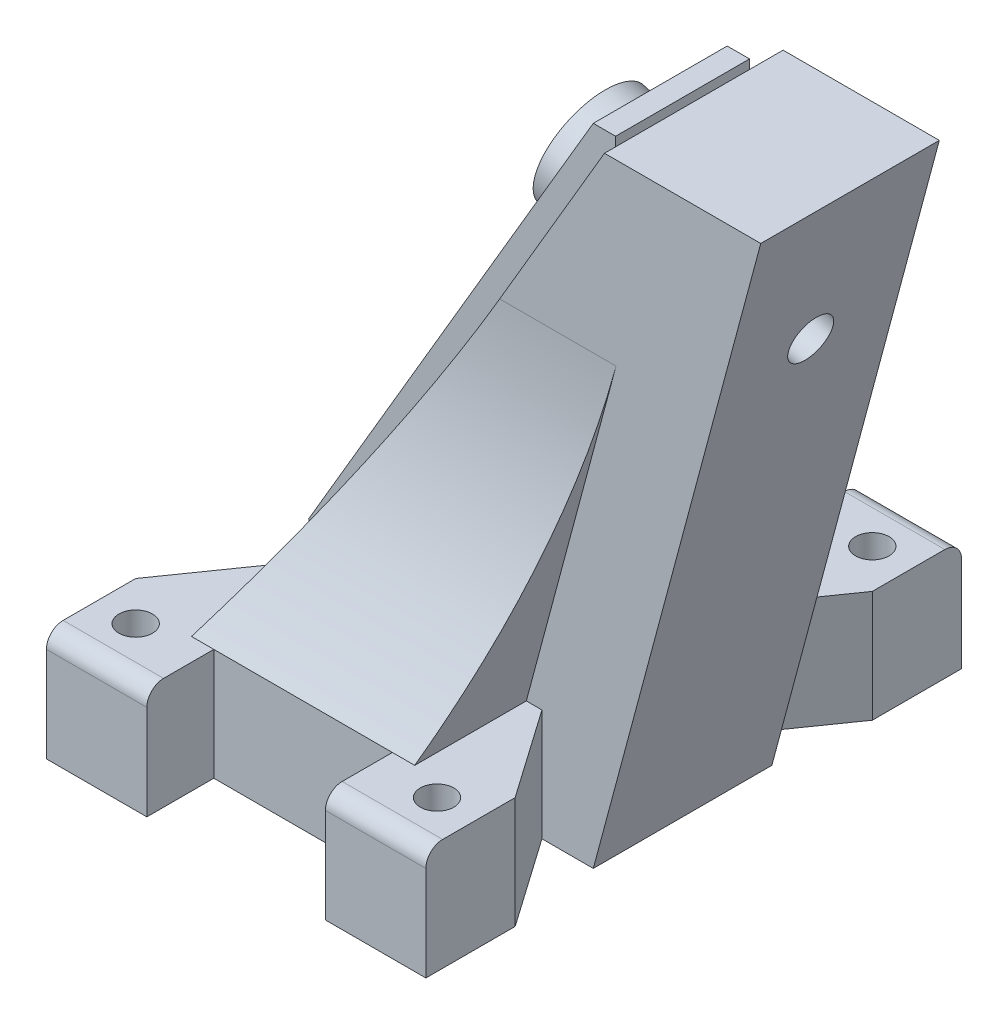
from build123d import *

# Parameters (mm, degrees)
BOSS_EXTRUDE1_DEPTH = 36
CUT_EXTRUDE1_REACH  = 77.774
SKETCH5_W           = 10
SKETCH5_H           = 10
CUT_EXTRUDE4_DEPTH  = 70.808427336
SKETCH6_W           = 10
SKETCH6_H           = 49.869122111
CUT_EXTRUDE5_DEPTH  = 8.383745
SKETCH7_R           = 1.5
BOSS_EXTRUDE2_DEPTH = 10
BOSS_EXTRUDE3_DEPTH = 6
SKETCH9_R           = 5
BOSS_EXTRUDE4_DEPTH = 20.4
CUT_EXTRUDE7_REACH  = 76.44
SKETCH12_R          = 2
FILLET1_R           = 1.5


with BuildPart() as part:
    # Sketch1 → Boss-Extrude1 (new body)
    with BuildSketch(Plane.XY):
        Polygon((0, 0), (-26, 0), (-26, 10), (1.005154776, 56), (15.005154776, 56), align=None)
    extrude(amount=BOSS_EXTRUDE1_DEPTH)

    # Sketch2 → Cut-Extrude1 (cut, up to next)
    with BuildSketch(Plane(origin=(-26, 3.422964937, 0), x_dir=(0, 0, -1), z_dir=(1, 0, 0)), mode=Mode.PRIVATE) as cut_extrude1_sk1:
        with BuildLine():
            Line((-26, 36.577035063), (-26, 52.577035063))
            Line((-26, 52.577035063), (-36, 52.577035063))
            Line((-36, 52.577035063), (-36, 6.577035063))
            ThreePointArc((-36, 6.577035063), (-28.565835097, 20.765646762), (-26, 36.577035063))
        make_face()
    cut_extrude1_tool1 = extrude(cut_extrude1_sk1.sketch, amount=CUT_EXTRUDE1_REACH, mode=Mode.PRIVATE) & part.part
    # Sketch2 → Cut-Extrude1 (cut, up to next)
    with BuildSketch(Plane(origin=(-26, 3.422964937, 0), x_dir=(0, 0, -1), z_dir=(1, 0, 0)), mode=Mode.PRIVATE) as cut_extrude1_sk2:
        with BuildLine():
            ThreePointArc((-10, 36.577035063), (-7.434164903, 20.765646762), (0, 6.577035063))
            Line((0, 6.577035063), (0, 52.577035063))
            Line((0, 52.577035063), (-10, 52.577035063))
            Line((-10, 52.577035063), (-10, 36.577035063))
        make_face()
    cut_extrude1_tool2 = extrude(cut_extrude1_sk2.sketch, amount=CUT_EXTRUDE1_REACH, mode=Mode.PRIVATE) & part.part
    # Sketch2 → Cut-Extrude1 (cut, up to next)
    with BuildSketch(Plane(origin=(-26, 3.422964937, 0), x_dir=(0, 0, -1), z_dir=(1, 0, 0)), mode=Mode.PRIVATE) as cut_extrude1_sk3:
        with BuildLine():
            ThreePointArc((-36, 6.577035063), (-28.565835097, 20.765646762), (-26, 36.577035063))
            Line((-26, 36.577035063), (-26, 52.577035063))
            Line((-26, 52.577035063), (-36, 52.577035063))
            Line((-36, 52.577035063), (-36, 6.577035063))
        make_face()
    cut_extrude1_tool3 = extrude(cut_extrude1_sk3.sketch, amount=CUT_EXTRUDE1_REACH, mode=Mode.PRIVATE) & part.part
    # Sketch2 → Cut-Extrude1 (cut, up to next)
    with BuildSketch(Plane(origin=(-26, 3.422964937, 0), x_dir=(0, 0, -1), z_dir=(1, 0, 0)), mode=Mode.PRIVATE) as cut_extrude1_sk4:
        with BuildLine():
            Line((0, 6.577035063), (0, 52.577035063))
            Line((0, 52.577035063), (-10, 52.577035063))
            Line((-10, 52.577035063), (-10, 36.577035063))
            ThreePointArc((-10, 36.577035063), (-7.434164903, 20.765646762), (0, 6.577035063))
        make_face()
    cut_extrude1_tool4 = extrude(cut_extrude1_sk4.sketch, amount=CUT_EXTRUDE1_REACH, mode=Mode.PRIVATE) & part.part
    add(cut_extrude1_tool1.solids().sort_by_distance((-26, 37.109216, 31.540478))[0], mode=Mode.SUBTRACT)
    add(cut_extrude1_tool2.solids().sort_by_distance((-26, 37.109216, 4.459522))[0], mode=Mode.SUBTRACT)
    add(cut_extrude1_tool3.solids().sort_by_distance((-26, 37.109216, 31.540478))[0], mode=Mode.SUBTRACT)
    add(cut_extrude1_tool4.solids().sort_by_distance((-26, 37.109216, 4.459522))[0], mode=Mode.SUBTRACT)

    # Sketch5 → Cut-Extrude4 (cut, through all)
    with BuildSketch(Plane.ZY.offset(6)):
        with Locations((31, 5)):
            Rectangle(SKETCH5_W, SKETCH5_H)
        with Locations((5, 5)):
            Rectangle(SKETCH5_W, SKETCH5_H)
    extrude(amount=-CUT_EXTRUDE4_DEPTH, mode=Mode.SUBTRACT)

    # Sketch6 → Cut-Extrude5 (cut)
    with BuildSketch(Plane(origin=(0, 0, 0), x_dir=(0, 0, -1), z_dir=(0.9659258262890674, -0.2588190451025246, 0))):
        with Locations((-31, 33.040905048)):
            Rectangle(SKETCH6_W, SKETCH6_H)
        with Locations((-5, 33.040905048)):
            Rectangle(SKETCH6_W, SKETCH6_H)
    extrude(amount=-CUT_EXTRUDE5_DEPTH, mode=Mode.SUBTRACT)

    # Sketch7 → Boss-Extrude2 (add)
    with BuildSketch(Plane.XZ):
        Polygon((-26, 24), (-33, 34), (-33, 42), (-24, 42), (-24, 36), (-26, 36), align=None)
        with Locations(Location((-29.5, 37.5, 0), (0, 0, 270))):
            Circle(SKETCH7_R, mode=Mode.SUBTRACT)
        Polygon((-26, 0), (-24, 0), (-24, -6), (-33, -6), (-33, 2), (-26, 12), align=None)
        with Locations(Location((-29.5, -1.5, 0), (0, 0, 90))):
            Circle(SKETCH7_R, mode=Mode.SUBTRACT)
        Polygon((-6, 12), (1, 2), (1, -6), (-8, -6), (-8, 0), (-6, 0), align=None)
        with Locations(Location((-2.5, -1.5, 0), (0, 0, 270))):
            Circle(SKETCH7_R, mode=Mode.SUBTRACT)
        Polygon((-6, 36), (-8, 36), (-8, 42), (1, 42), (1, 34), (-6, 24), align=None)
        with Locations(Location((-2.5, 37.5, 0), (0, 0, 90))):
            Circle(SKETCH7_R, mode=Mode.SUBTRACT)
    extrude(amount=-BOSS_EXTRUDE2_DEPTH)

    # Sketch8 → Boss-Extrude3 (add, symmetric)
    with BuildSketch(Plane.XY.offset(18)):
        Polygon((-26, 5), (-26, 10), (0, 54.287840966), (0, 55.819136666), (-2, 55.819136666), (-27.5, 12.382984949), align=None)
    extrude(amount=BOSS_EXTRUDE3_DEPTH, both=True)

    # Sketch9 → Boss-Extrude4 (add)
    with BuildSketch(Plane(origin=(0, 0, 0), x_dir=(0, 0, -1), z_dir=(-0.9659258262890674, 0.2588190451025246, 0))):
        with Locations(Location((-18, -44.351999472, 0), (0, 0, 270))):
            Circle(SKETCH9_R)
    extrude(amount=BOSS_EXTRUDE4_DEPTH)

    # Sketch12 → Cut-Extrude7 (cut, up to next)
    with BuildSketch(Plane(origin=(-19.704886856, 5.27990852, 0), x_dir=(0, 0, 1), z_dir=(-0.9659258262890673, 0.2588190451025247, 0)), mode=Mode.PRIVATE) as cut_extrude7_sk1:
        with Locations(Location((18, 44.351999472, 0), (0, 0, 270))):
            Circle(SKETCH12_R)
    cut_extrude7_tool1 = extrude(cut_extrude7_sk1.sketch, amount=-CUT_EXTRUDE7_REACH, mode=Mode.PRIVATE) & part.part
    add(cut_extrude7_tool1.solids().sort_by_distance((-8.225745, 48.12065, 18))[0], mode=Mode.SUBTRACT)

    # Fillet1
    fillet1_edges = [part.edges().sort_by_distance(p)[0] for p in [
        (-28.5, 10, 42),
        (-28.5, 10, -6),
        (-3.5, 10, -6),
        (-3.5, 10, 42),
    ]]
    fillet(fillet1_edges, radius=FILLET1_R)


solid = part.part
